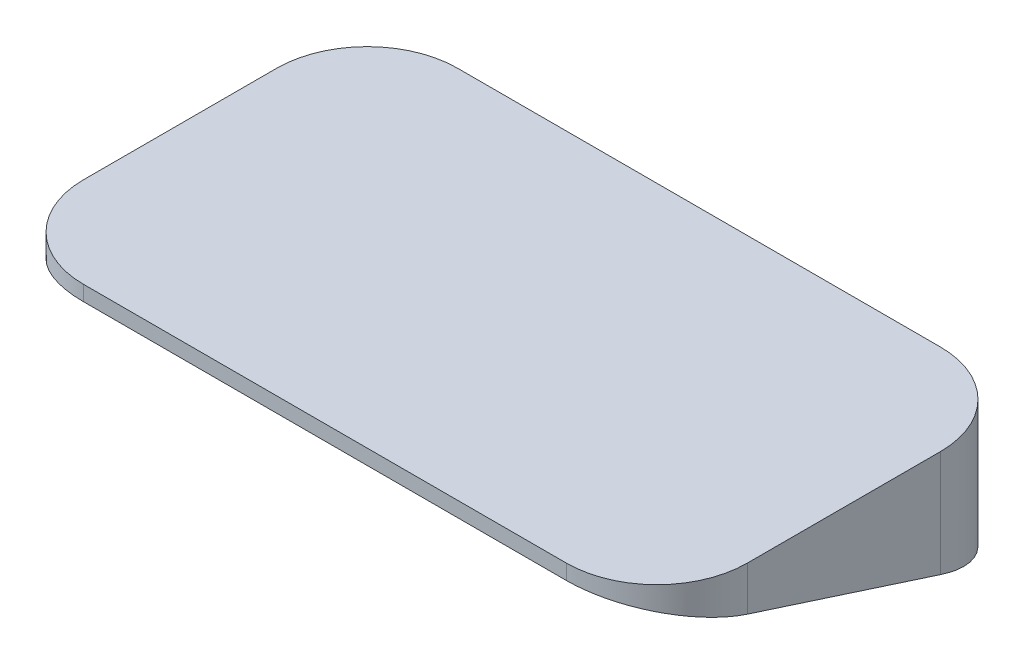
from build123d import *

# Parameters (mm, degrees)
BOSS_EXTRUDE1_DEPTH = 45
CUT_EXTRUDE2_DEPTH  = 43
CUT_EXTRUDE4_DEPTH  = 264


with BuildPart() as part:
    # Sketch1 → Boss-Extrude1 (new body)
    with BuildSketch(Plane(origin=(0, 0, 0), x_dir=(1, 0, 0), z_dir=(0, 1, 0))):
        with BuildLine():
            Line((-80, 62), (80, 62))
            ThreePointArc((80, 62), (101.213203436, 53.213203436), (110, 32))
            Line((110, 32), (110, -32))
            ThreePointArc((110, -32), (101.213203436, -53.213203436), (80, -62))
            Line((80, -62), (-80, -62))
            ThreePointArc((-80, -62), (-101.213203436, -53.213203436), (-110, -32))
            Line((-110, -32), (-110, 32))
            ThreePointArc((-110, 32), (-101.213203436, 53.213203436), (-80, 62))
        make_face()
    extrude(amount=BOSS_EXTRUDE1_DEPTH)

    # Sketch6 → Cut-Extrude2 (cut)
    with BuildSketch(Plane.XZ):
        with BuildLine():
            Line((80, 60), (-80, 60))
            ThreePointArc((-80, 60), (-99.798989873, 51.798989873), (-108, 32))
            Line((-108, 32), (-108, -32))
            ThreePointArc((-108, -32), (-99.798989873, -51.798989873), (-80, -60))
            Line((-80, -60), (80, -60))
            ThreePointArc((80, -60), (99.798989873, -51.798989873), (108, -32))
            Line((108, -32), (108, 32))
            ThreePointArc((108, 32), (99.798989873, 51.798989873), (80, 60))
        make_face()
    extrude(amount=-CUT_EXTRUDE2_DEPTH, mode=Mode.SUBTRACT)

    # Sketch4 → Cut-Extrude4 (cut)
    with BuildSketch(Plane(origin=(110, 0, 0), x_dir=(0, 0, -1), z_dir=(1, 0, 0))):
        Polygon((-32, 30.322580645), (-62, 40), (-62, 0), (-32, 0), align=None)
        Polygon((32, 9.677419355), (-32, 30.322580645), (-32, 0), (32, 0), align=None)
        Polygon((62, 0), (32, 9.677419355), (32, 0), align=None)
    extrude(amount=-CUT_EXTRUDE4_DEPTH, mode=Mode.SUBTRACT)


solid = part.part
